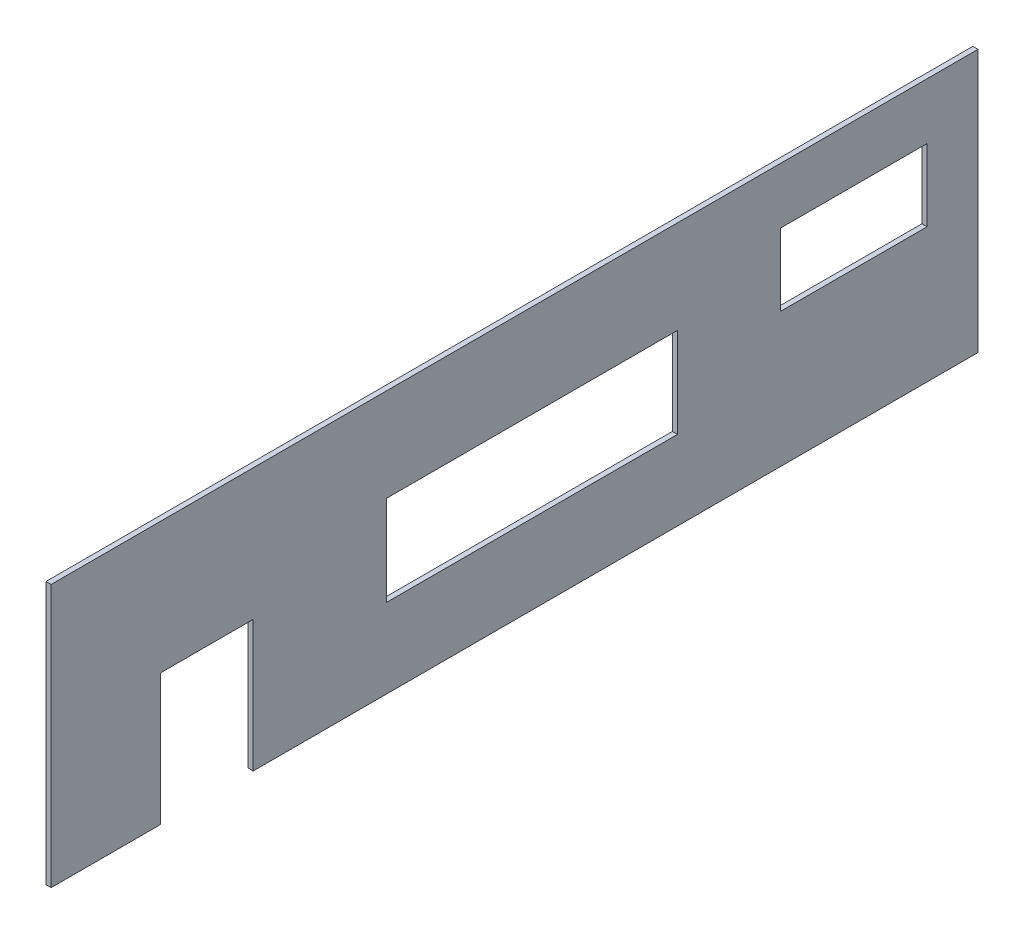
from build123d import *

# Parameters (mm, degrees)
SKETCH1_W           = 360
SKETCH1_H           = 102
BOSS_EXTRUDE1_DEPTH = 2
SKETCH2_W           = 36
SKETCH2_H           = 51
SKETCH2_W_2         = 113
SKETCH2_H_2         = 35
CUT_EXTRUDE1_DEPTH  = 10
SKETCH3_W           = 57
SKETCH3_H           = 28
CUT_EXTRUDE2_DEPTH  = 10


with BuildPart() as part:
    # Sketch1 → Boss-Extrude1 (new body)
    with BuildSketch(Plane(origin=(0, 0, 0), x_dir=(0, 0, -1), z_dir=(1, 0, 0))):
        with Locations((62.608695652, 70.304347826)):
            Rectangle(SKETCH1_W, SKETCH1_H)
    extrude(amount=BOSS_EXTRUDE1_DEPTH)

    # Sketch2 → Cut-Extrude1 (cut)
    with BuildSketch(Plane.ZY):
        with Locations((56.914343826, 44.804347826)):
            Rectangle(SKETCH2_W, SKETCH2_H)
        with Locations((-69.366260537, 67.630807185)):
            Rectangle(SKETCH2_W_2, SKETCH2_H_2)
    extrude(amount=-CUT_EXTRUDE1_DEPTH, mode=Mode.SUBTRACT)

    # Sketch3 → Cut-Extrude2 (cut)
    with BuildSketch(Plane.ZY):
        with Locations((-194.333824882, 85.510777566)):
            Rectangle(SKETCH3_W, SKETCH3_H)
    extrude(amount=-CUT_EXTRUDE2_DEPTH, mode=Mode.SUBTRACT)


solid = part.part
